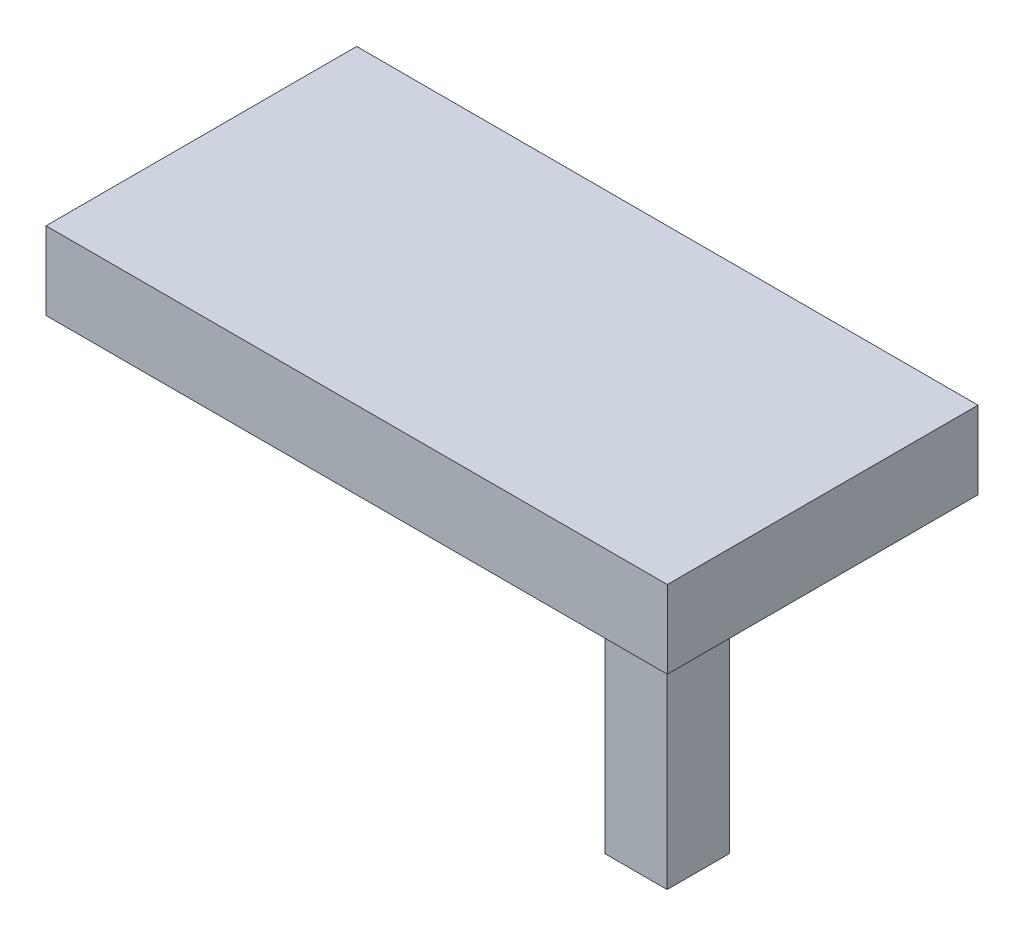
from build123d import *

# Parameters (mm, degrees)
SKETCH2_W           = 2000
SKETCH2_H           = 1000
BOSS_EXTRUDE1_DEPTH = 250
SKETCH3_W           = 500
SKETCH3_H           = 503.161668984
BOSS_EXTRUDE2_DEPTH = 100
SKETCH4_W           = 200
SKETCH4_H           = 201.264667594
BOSS_EXTRUDE3_DEPTH = 900


with BuildPart() as part:
    # Sketch2 → Boss-Extrude1 (new body)
    with BuildSketch(Plane(origin=(0, 0, 0), x_dir=(1, 0, 0), z_dir=(0, 1, 0))):
        Rectangle(SKETCH2_W, SKETCH2_H)
    extrude(amount=BOSS_EXTRUDE1_DEPTH)

    # Sketch3 → Boss-Extrude2 (add)
    with BuildSketch(Plane.XZ):
        with Locations((-500, 0)):
            Rectangle(SKETCH3_W, SKETCH3_H)
        with Locations((500, 0)):
            Rectangle(SKETCH3_W, SKETCH3_H)
    extrude(amount=BOSS_EXTRUDE2_DEPTH)

    # Sketch4 → Boss-Extrude3 (add)
    with BuildSketch(Plane.XZ.offset(100)):
        with Locations((500, 0)):
            Rectangle(SKETCH4_W, SKETCH4_H)
    extrude(amount=BOSS_EXTRUDE3_DEPTH)


solid = part.part
